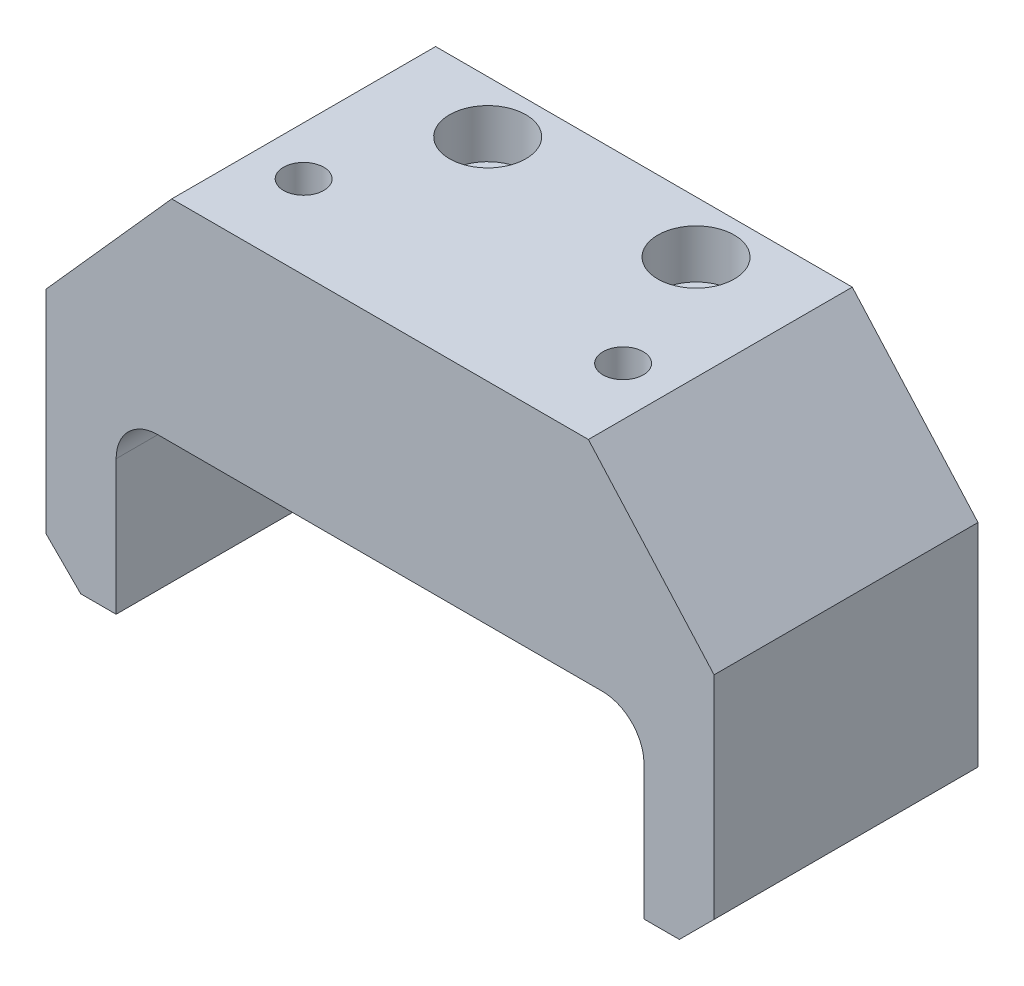
from build123d import *

# Parameters (mm, degrees)
BOSS_EXTRUDE1_DEPTH = 19
CUT_EXTRUDE8_DEPTH  = 39
FILLET1_R           = 6
SKETCH2_R           = 3.05
CUT_EXTRUDE1_DEPTH  = 42
SKETCH3_R           = 5.5
CUT_EXTRUDE2_DEPTH  = 7
SKETCH8_R           = 2.9
CUT_EXTRUDE7_DEPTH  = 23
CHAMFER2_SIZE       = 5


with BuildPart() as part:
    # Sketch1 → Boss-Extrude1 (new body, symmetric)
    with BuildSketch(Plane.XY):
        Polygon((48.1, 6), (-48.1, 6), (-48.1, -49.8), (-38, -49.8), (-38, -24.4), (38, -24.4), (38, -49.8), (48.1, -49.8), align=None)
    extrude(amount=BOSS_EXTRUDE1_DEPTH, both=True)

    # Sketch9 → Cut-Extrude8 (cut, through all)
    with BuildSketch(Plane.XY.offset(19)):
        Polygon((-30, 6), (-48.1, -14.3), (-48.1, 6), align=None)
        Polygon((48.1, 6), (30, 6), (48.1, -14.3), align=None)
    extrude(amount=-CUT_EXTRUDE8_DEPTH, mode=Mode.SUBTRACT)

    # Fillet1
    fillet1_edges = [part.edges().sort_by_distance(p)[0] for p in [
        (38, -24.4, 0),
        (-38, -24.4, 0),
    ]]
    fillet(fillet1_edges, radius=FILLET1_R)

    # Sketch2 → Cut-Extrude1 (cut)
    with BuildSketch(Plane(origin=(0, 6, 0), x_dir=(1, 0, 0), z_dir=(0, 1, 0))):
        with Locations((-15, 11.5)):
            Circle(SKETCH2_R)
        with Locations((15, 11.5)):
            Circle(SKETCH2_R)
    extrude(amount=-CUT_EXTRUDE1_DEPTH, mode=Mode.SUBTRACT)

    # Sketch3 → Cut-Extrude2 (cut)
    with BuildSketch(Plane(origin=(0, 6, 0), x_dir=(1, 0, 0), z_dir=(0, 1, 0))):
        with Locations((-15, 11.5)):
            Circle(SKETCH3_R)
        with Locations((15, 11.5)):
            Circle(SKETCH3_R)
    extrude(amount=-CUT_EXTRUDE2_DEPTH, mode=Mode.SUBTRACT)

    # Sketch8 → Cut-Extrude7 (cut)
    with BuildSketch(Plane(origin=(0, 6, 0), x_dir=(1, 0, 0), z_dir=(0, 1, 0))):
        with Locations((-23, -7)):
            Circle(SKETCH8_R)
        with Locations((23, -7)):
            Circle(SKETCH8_R)
    extrude(amount=-CUT_EXTRUDE7_DEPTH, mode=Mode.SUBTRACT)

    # Chamfer2
    chamfer2_edges = [part.edges().sort_by_distance(p)[0] for p in [
        (48.1, -49.8, 0),
        (-48.1, -49.8, 0),
    ]]
    chamfer(chamfer2_edges, length=CHAMFER2_SIZE)


solid = part.part
